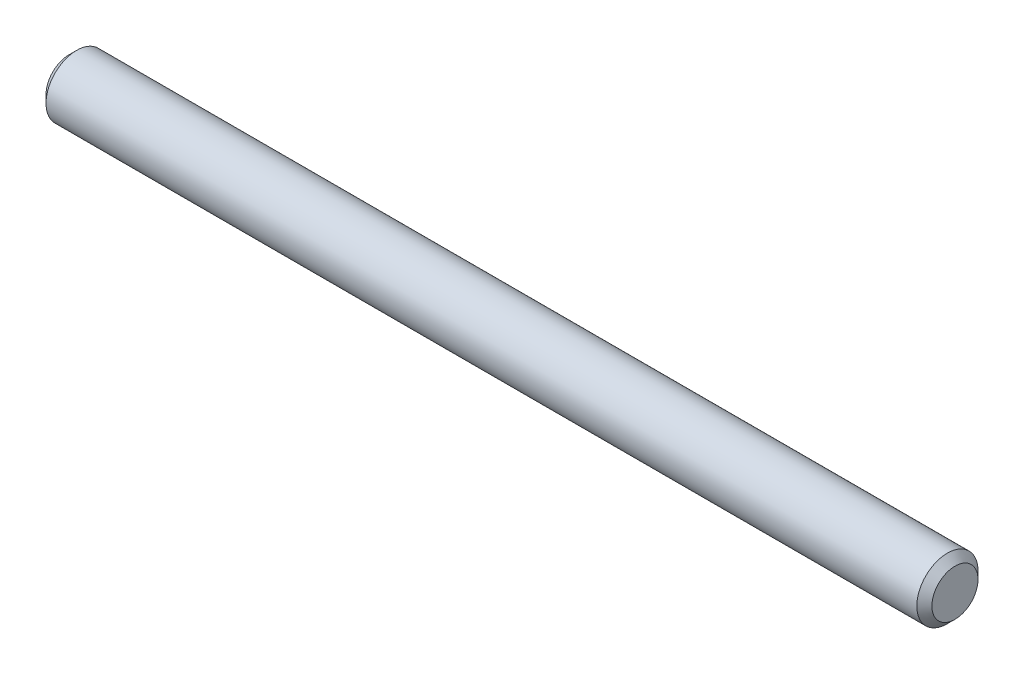
from build123d import *

# Parameters (mm, degrees)
SKETCH2_R                = 2.413
BOSS_EXTRUDE1_DEPTH      = 34.925
BOSS_EXTRUDE1_DEPTH_BACK = 34.925
CHAMFER1_SIZE            = 0.5953125


with BuildPart() as part:
    # Sketch2 → Boss-Extrude1 (new body, two sides)
    with BuildSketch(Plane(origin=(0, 0, 0), x_dir=(0, 0, -1), z_dir=(1, 0, 0))) as boss_extrude1_sk:
        Circle(SKETCH2_R)
    extrude(amount=BOSS_EXTRUDE1_DEPTH)
    extrude(boss_extrude1_sk.sketch, amount=-BOSS_EXTRUDE1_DEPTH_BACK)

    # Chamfer1
    chamfer1_edges = [part.edges().sort_by_distance(p)[0] for p in [
        (-34.925, 0, 2.413),
        (34.925, 0, 2.413),
    ]]
    chamfer(chamfer1_edges, length=CHAMFER1_SIZE)


solid = part.part
